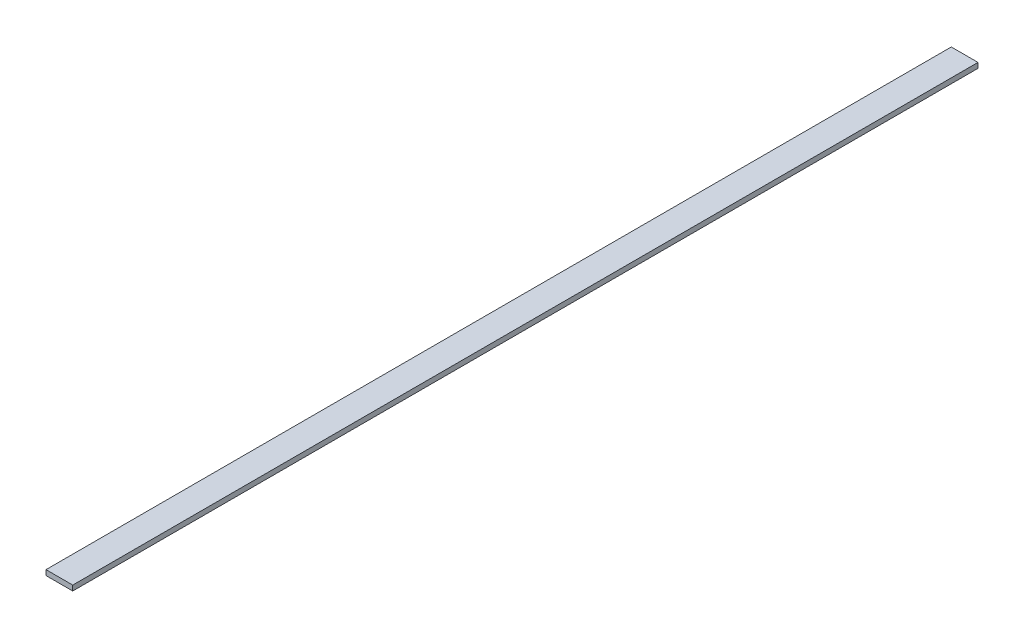
from build123d import *

# Parameters (mm, degrees)
CROQUIS1_W              = 31
CROQUIS1_H              = 6
SALIENTE_EXTRUIR1_DEPTH = 1050


with BuildPart() as part:
    # Croquis1 → Saliente-Extruir1 (new body)
    with BuildSketch(Plane.XY):
        with Locations((15.5, 3)):
            Rectangle(CROQUIS1_W, CROQUIS1_H)
    extrude(amount=-SALIENTE_EXTRUIR1_DEPTH)


solid = part.part
